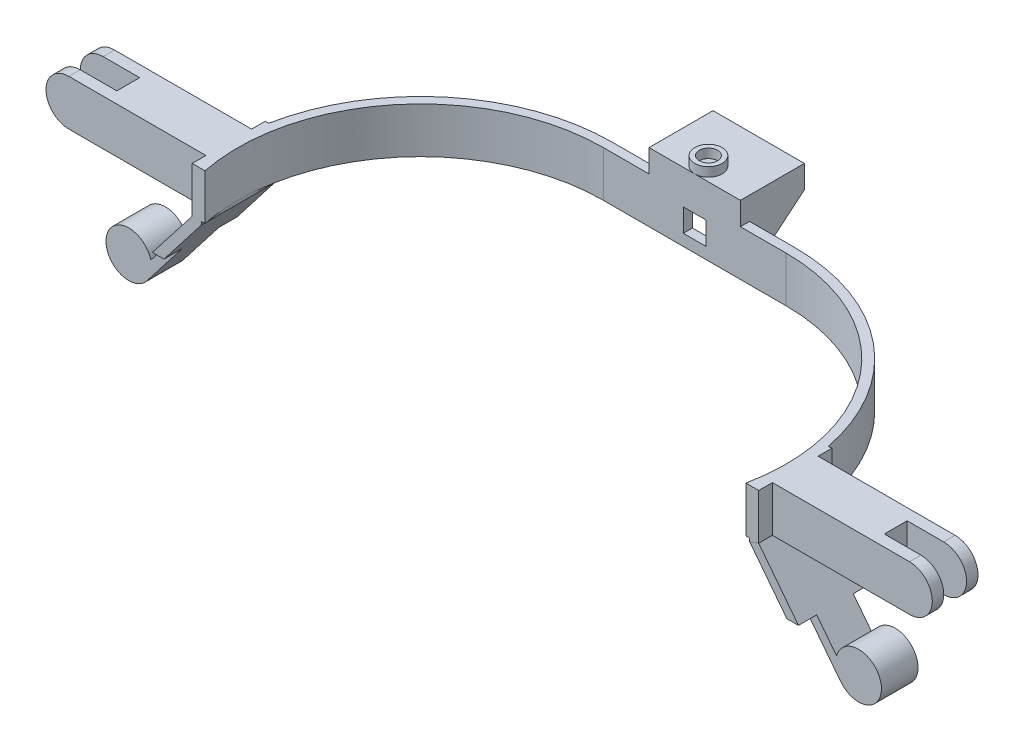
from build123d import *

# Parameters (mm, degrees)
EXTRUDE_1_DEPTH           = 20
SKETCH_18_W               = 10
SKETCH_18_H               = 10
CUT_EXTRUDE_6_DEPTH       = 10
SKETCH_20_W               = 40
SKETCH_20_H               = 4
EXTRUDE_5_DEPTH           = 10
SKETCH_8_W                = 4
SKETCH_8_H                = 32
SKETCH_25_W               = 246.903686524
SKETCH_25_H               = 75.06139437
CUT_EXTRUDE_7_DEPTH       = 30
SKETCH_11_W               = 4
SKETCH_11_H               = 32
SKETCH_26_W               = 20
SKETCH_26_H               = 20
EXTRUDE_6_DEPTH           = 70
SKETCH_28_W               = 20
SKETCH_28_H               = 20
EXTRUDE_7_DEPTH           = 70
SKETCH_29_W               = 26
SKETCH_29_H               = 10
CUT_EXTRUDE_8_DEPTH       = 20
SKETCH_31_R               = 10
CUT_EXTRUDE_10_DEPTH      = 101
SKETCH_32_R               = 10
EXTRUDE_8_DEPTH           = 8
CUT_EXTRUDE_11_DEPTH      = 95
EXTRUDE_9_DEPTH           = 24
CUT_EXTRUDE_12_DEPTH      = 215
SKETCH_36_R               = 6
SKETCH_36_R_2             = 4
EXTRUDE_10_DEPTH          = 4
SKETCH_38_W               = 10.504176023
SKETCH_38_H               = 23.874283345
SKETCH_38_W_2             = 11.702143621
CUT_EXTRUDE_13_DEPTH      = 195
CUT_EXTRUDE_13_DEPTH_BACK = 195


with BuildPart() as part:
    # 草图2 → 凸台-拉伸1 (new body)
    with BuildSketch(Plane(origin=(0, 0, 0), x_dir=(1, 0, 0), z_dir=(0, 1, 0))):
        with BuildLine():
            Line((-40, 84), (40, 84))
            ThreePointArc((40, 84), (124, 0), (40, -84))
            Line((40, -84), (-40, -84))
            ThreePointArc((-40, -84), (-124, 0), (-40, 84))
        make_face()
        with BuildLine():
            Line((-40, 80), (40, 80))
            ThreePointArc((40, 80), (120, 0), (40, -80))
            Line((40, -80), (-40, -80))
            ThreePointArc((-40, -80), (-120, 0), (-40, 80))
        make_face(mode=Mode.SUBTRACT)
    extrude(amount=EXTRUDE_1_DEPTH)

    # 草图18 → 切除-拉伸6 (cut)
    with BuildSketch(Plane(origin=(0, 0, -84), x_dir=(-1, 0, 0), z_dir=(0, 0, -1))):
        with Locations((0, 10)):
            Rectangle(SKETCH_18_W, SKETCH_18_H)
    extrude(amount=-CUT_EXTRUDE_6_DEPTH, mode=Mode.SUBTRACT)

    # 草图20 → 凸台-拉伸5 (add)
    with BuildSketch(Plane(origin=(0, 20, 0), x_dir=(1, 0, 0), z_dir=(0, 1, 0))):
        with Locations((0, 82)):
            Rectangle(SKETCH_20_W, SKETCH_20_H)
    extrude(amount=EXTRUDE_5_DEPTH)

    # 扫描1: sweep along a path in 草图9
    with BuildLine(Plane.XY) as sweep_1_path:
        Line((-124, 20), (-124, 0))
        Line((-124, 0), (-155, -40))
    # 草图8 → 扫描1 (sweep)
    with BuildSketch(Plane(origin=(0, 20, 0), x_dir=(1, 0, 0), z_dir=(0, 1, 0))):
        with Locations((-122, 0)):
            Rectangle(SKETCH_8_W, SKETCH_8_H)
    sweep(path=sweep_1_path.line, transition=Transition.RIGHT)

    # 草图25 → 切除-拉伸7 (cut)
    with BuildSketch(Plane(origin=(0, 20, 0), x_dir=(1, 0, 0), z_dir=(0, 1, 0))):
        with Locations((0.98973075, -53.530697185)):
            Rectangle(SKETCH_25_W, SKETCH_25_H)
    extrude(amount=-CUT_EXTRUDE_7_DEPTH, mode=Mode.SUBTRACT)

    # 扫描2: sweep along a path in 草图27
    with BuildLine(Plane.XY) as sweep_2_path:
        Line((124, 20), (124, 0))
        Line((124, 0), (155, -40))
    # 草图11 → 扫描2 (sweep)
    with BuildSketch(Plane(origin=(0, 20, 0), x_dir=(1, 0, 0), z_dir=(0, 1, 0))):
        with Locations((122, 0)):
            Rectangle(SKETCH_11_W, SKETCH_11_H)
    sweep(path=sweep_2_path.line, transition=Transition.RIGHT)

    # 草图26 → 凸台-拉伸6 (add)
    with BuildSketch(Plane.ZY.offset(124)):
        with Locations((0, 10)):
            Rectangle(SKETCH_26_W, SKETCH_26_H)
    extrude(amount=EXTRUDE_6_DEPTH)

    # 草图28 → 凸台-拉伸7 (add)
    with BuildSketch(Plane(origin=(124, 0, 0), x_dir=(0, 0, -1), z_dir=(1, 0, 0))):
        with Locations((0, 10)):
            Rectangle(SKETCH_28_W, SKETCH_28_H)
    extrude(amount=EXTRUDE_7_DEPTH)

    # 草图29 → 切除-拉伸8 (cut)
    with BuildSketch(Plane(origin=(0, 20, 0), x_dir=(1, 0, 0), z_dir=(0, 1, 0))):
        with Locations((-181, 0)):
            Rectangle(SKETCH_29_W, SKETCH_29_H)
        with Locations((181, 0)):
            Rectangle(SKETCH_29_W, SKETCH_29_H)
    extrude(amount=-CUT_EXTRUDE_8_DEPTH, mode=Mode.SUBTRACT)

    # 草图31 → 切除-拉伸10 (cut, through all)
    with BuildSketch(Plane.XY.offset(16)):
        with Locations((-159.742490313, -36.324570007)):
            Circle(SKETCH_31_R)
        with Locations((159.742490313, -36.324570007)):
            Circle(SKETCH_31_R)
    extrude(amount=-CUT_EXTRUDE_10_DEPTH, mode=Mode.SUBTRACT)

    # 草图32 → 凸台-拉伸8 (add, symmetric)
    with BuildSketch(Plane.XY):
        with Locations((-159.742490313, -36.324570007)):
            Circle(SKETCH_32_R)
        with Locations((159.742490313, -36.324570007)):
            Circle(SKETCH_32_R)
    extrude(amount=EXTRUDE_8_DEPTH, both=True)

    # 草图33 → 切除-拉伸11 (cut, through all)
    with BuildSketch(Plane.XY.offset(10)):
        with BuildLine():
            Line((-184, 20), (-199.388740024, 20))
            Line((-199.388740024, 20), (-199.388740024, 0))
            Line((-199.388740024, 0), (-184, 0))
            ThreePointArc((-184, 0), (-194, 10), (-184, 20))
        make_face()
        with BuildLine():
            Line((184, 20), (198.413524526, 20))
            Line((198.413524526, 20), (198.413524526, 0))
            Line((198.413524526, 0), (184, 0))
            ThreePointArc((184, 0), (194, 10), (184, 20))
        make_face()
    extrude(amount=-CUT_EXTRUDE_11_DEPTH, mode=Mode.SUBTRACT)

    # 草图34 → 凸台-拉伸9 (add)
    with BuildSketch(Plane(origin=(0, 0, -84), x_dir=(-1, 0, 0), z_dir=(0, 0, -1))):
        Polygon((20, 30), (-20, 30), (-20, 20), (-20, 0), (-12, 0), (-12, 20), (12, 20), (12, 0), (20, 0), (20, 20), align=None)
    extrude(amount=EXTRUDE_9_DEPTH)

    # 草图35 → 切除-拉伸12 (cut, through all)
    with BuildSketch(Plane(origin=(20, 0, 0), x_dir=(0, 0, -1), z_dir=(1, 0, 0))):
        Polygon((108, 20), (84, 0), (110.80524342, 0), align=None)
    extrude(amount=-CUT_EXTRUDE_12_DEPTH, mode=Mode.SUBTRACT)

    # 草图36 → 凸台-拉伸10 (add)
    with BuildSketch(Plane(origin=(0, 30, 0), x_dir=(1, 0, 0), z_dir=(0, 1, 0))):
        with Locations((0, 86)):
            Circle(SKETCH_36_R)
        with Locations((0, 86)):
            Circle(SKETCH_36_R_2, mode=Mode.SUBTRACT)
    extrude(amount=EXTRUDE_10_DEPTH)

    # 草图38 → 切除-拉伸13 (cut, two sides)
    with BuildSketch(Plane(origin=(0, 0, 0), x_dir=(0, 0, -1), z_dir=(1, 0, 0))) as cut_extrude_13_sk:
        with Locations((-13.252088011, -34.387428335)):
            Rectangle(SKETCH_38_W, SKETCH_38_H)
        with Locations((13.851071811, -34.387428335)):
            Rectangle(SKETCH_38_W_2, SKETCH_38_H)
    extrude(amount=CUT_EXTRUDE_13_DEPTH, mode=Mode.SUBTRACT)
    extrude(cut_extrude_13_sk.sketch, amount=-CUT_EXTRUDE_13_DEPTH_BACK, mode=Mode.SUBTRACT)


solid = part.part
